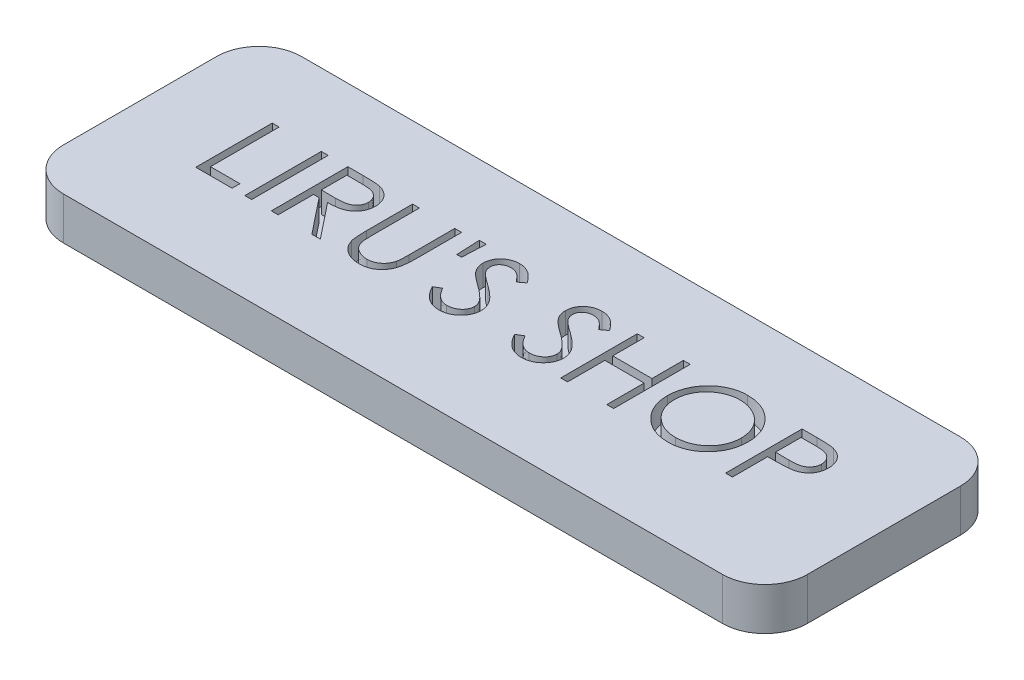
from build123d import *

# Parameters (mm, degrees)
SKETCH1_W           = 175
SKETCH1_H           = 56
BOSS_EXTRUDE1_DEPTH = 10
SKETCH2_W           = 1.615384615
SKETCH2_H           = 18
CUT_EXTRUDE1_DEPTH  = 5
FILLET1_R           = 10


with BuildPart() as part:
    # Sketch1 → Boss-Extrude1 (new body)
    with BuildSketch(Plane(origin=(0, 0, 0), x_dir=(1, 0, 0), z_dir=(0, 1, 0))):
        Rectangle(SKETCH1_W, SKETCH1_H)
    extrude(amount=BOSS_EXTRUDE1_DEPTH)

    # Sketch2 → Cut-Extrude1 (cut)
    with BuildSketch(Plane(origin=(0, 10, 0), x_dir=(1, 0, 0), z_dir=(0, 1, 0))):
        Polygon((-67.384615385, 11), (-65.769230769, 11), (-65.769230769, -5.153846154), (-58.846153846, -5.153846154), (-58.846153846, -7), (-67.384615385, -7), align=None)
        with Locations((-55.038461539, 2)):
            Rectangle(SKETCH2_W, SKETCH2_H)
        with BuildLine():
            Line((-49.615384615, 11), (-46.013221154, 11))
            add(Edge.make_bspline(
                [(-46.013221154, 11), (-45.772838207, 10.999199843), (-45.311276322, 10.997663454), (-44.65004236, 10.989096674), (-44.04921729, 10.964542844), (-43.509115259, 10.943412986), (-43.029746176, 10.904883002), (-42.609640109, 10.868056817), (-42.250731951, 10.819849419), (-42.033467573, 10.775078672), (-41.935096154, 10.754807692)],
                knots=[0, 0, 0, 0, 0.000721163, 0.001384713, 0.001983661, 0.002525115, 0.003006036, 0.003426182, 0.003790275, 0.004091524, 0.004091524, 0.004091524, 0.004091524], degree=3))
            add(Edge.make_bspline(
                [(-41.935096154, 10.754807692), (-41.803404944, 10.722270042), (-41.542831855, 10.657888857), (-41.167660087, 10.52181091), (-40.81015785, 10.364338555), (-40.471810182, 10.179382279), (-40.154311827, 9.965569127), (-39.854389086, 9.726590211), (-39.570680988, 9.463753153), (-39.314661176, 9.170431111), (-39.073260339, 8.86270049), (-38.869661688, 8.529938312), (-38.694154078, 8.181964742), (-38.554419991, 7.815240879), (-38.441904699, 7.433323195), (-38.362569753, 7.03275224), (-38.314992217, 6.61535294), (-38.310148388, 6.330655123), (-38.307692308, 6.186298077)],
                knots=[0, 0, 0, 0, 0.000406701, 0.000804727, 0.001195366, 0.001577816, 0.00195984, 0.002342205, 0.002727415, 0.003118188, 0.003509078, 0.003899318, 0.004286329, 0.00467672, 0.005074941, 0.00547943, 0.005900318, 0.006333251, 0.006333251, 0.006333251, 0.006333251], degree=3))
            add(Edge.make_bspline(
                [(-38.307692308, 6.186298077), (-38.315247155, 5.946460396), (-38.329988619, 5.478474961), (-38.46743201, 4.799304714), (-38.692568397, 4.165759667), (-39.002802454, 3.578637529), (-39.397874044, 3.049382782), (-39.872687255, 2.584517583), (-40.427506971, 2.195512318), (-40.944000596, 1.925755037), (-41.400245052, 1.752991507), (-41.775844946, 1.63143309), (-42.18556083, 1.537514411), (-42.625467123, 1.453376591), (-43.097394494, 1.389853591), (-43.600211839, 1.343328248), (-44.134277762, 1.314250283), (-44.501164404, 1.309919972), (-44.689903846, 1.307692308)],
                knots=[0, 0, 0, 0, 0.000718851, 0.001402665, 0.002068709, 0.00273005, 0.003387023, 0.004042331, 0.00471467, 0.00541297, 0.005783944, 0.00617737, 0.006596291, 0.007043944, 0.007520738, 0.008024128, 0.00855856, 0.00912477, 0.00912477, 0.00912477, 0.00912477], degree=3))
            Line((-44.689903846, 1.307692308), (-38.076923077, -7))
            Line((-38.076923077, -7), (-40.074519231, -7))
            Line((-40.074519231, -7), (-46.6875, 1.307692308))
            Line((-46.6875, 1.307692308), (-48, 1.307692308))
            Line((-48, 1.307692308), (-48, -7))
            Line((-48, -7), (-49.615384615, -7))
            Line((-49.615384615, -7), (-49.615384615, 11))
        make_face()
        with BuildLine():
            Line((-48, 9.153846154), (-48, 3.153846154))
            Line((-48, 3.153846154), (-44.704326923, 3.128605769))
            add(Edge.make_bspline(
                [(-44.704326923, 3.128605769), (-44.550452437, 3.128537695), (-44.252199858, 3.128405748), (-43.820710724, 3.148945168), (-43.41895015, 3.172310805), (-43.048454853, 3.208050296), (-42.709059323, 3.254110094), (-42.400933198, 3.311725441), (-42.123573502, 3.378850335), (-41.800095305, 3.482744411), (-41.438878858, 3.64734679), (-41.046317064, 3.886826498), (-40.712019327, 4.188039111), (-40.429584607, 4.532474027), (-40.202633245, 4.911174736), (-40.042628394, 5.319601777), (-39.941095834, 5.747444281), (-39.929120457, 6.041503122), (-39.923076923, 6.189903846)],
                knots=[0, 0, 0, 0, 0.000461553, 0.00089462, 0.001295656, 0.001668796, 0.002010965, 0.002322838, 0.002608809, 0.002866515, 0.003340999, 0.003796212, 0.004240586, 0.004683802, 0.005128424, 0.005558963, 0.00599544, 0.006440135, 0.006440135, 0.006440135, 0.006440135], degree=3))
            add(Edge.make_bspline(
                [(-39.923076923, 6.189903846), (-39.92925926, 6.334657654), (-39.941510396, 6.621506881), (-40.041532634, 7.041451563), (-40.210678024, 7.437795878), (-40.438620962, 7.808927515), (-40.716330902, 8.145814156), (-41.041965367, 8.434056658), (-41.406620657, 8.671911048), (-41.747443962, 8.823905005), (-42.052077055, 8.917092821), (-42.31657245, 8.982670235), (-42.615431478, 9.035356075), (-42.950105265, 9.07756896), (-43.319165081, 9.11385153), (-43.724477, 9.138289249), (-44.16335187, 9.15276055), (-44.467536088, 9.153475864), (-44.625, 9.153846154)],
                knots=[0, 0, 0, 0, 0.000433908, 0.000859846, 0.001286441, 0.001721799, 0.002162235, 0.002591337, 0.003021392, 0.003463654, 0.003705429, 0.003976533, 0.00428066, 0.004615201, 0.004988342, 0.005392976, 0.005833116, 0.006305486, 0.006305486, 0.006305486, 0.006305486], degree=3))
            Line((-44.625, 9.153846154), (-48, 9.153846154))
        make_face(mode=Mode.SUBTRACT)
        with BuildLine():
            Line((-34.384615385, 11), (-32.769230769, 11))
            Line((-32.769230769, 11), (-32.769230769, 0.215144231))
            add(Edge.make_bspline(
                [(-32.769230769, 0.215144231), (-32.769471167, 0.062500447), (-32.769927363, -0.227167438), (-32.766880148, -0.639461555), (-32.758346254, -1.00600563), (-32.752966005, -1.32821256), (-32.740996861, -1.604603833), (-32.731235477, -1.836676859), (-32.718684042, -2.023332758), (-32.703599438, -2.132263235), (-32.697115385, -2.179086538)],
                knots=[0, 0, 0, 0, 0.000457933, 0.000869006, 0.001236865, 0.00155786, 0.001835715, 0.002066737, 0.002254791, 0.002396567, 0.002396567, 0.002396567, 0.002396567], degree=3))
            add(Edge.make_bspline(
                [(-32.697115385, -2.179086538), (-32.670488454, -2.34801275), (-32.618734924, -2.676346786), (-32.486839267, -3.143875092), (-32.302634976, -3.565236878), (-32.08435647, -3.95358066), (-31.796703041, -4.298097369), (-31.452113431, -4.615471584), (-31.034627764, -4.893040865), (-30.570430363, -5.14684504), (-30.070106285, -5.350836892), (-29.558848343, -5.50508848), (-29.044341593, -5.59909425), (-28.699892745, -5.609979308), (-28.528846154, -5.615384615)],
                knots=[0, 0, 0, 0, 0.000512793, 0.000996692, 0.001452162, 0.001890022, 0.002328164, 0.002792651, 0.003290717, 0.003827989, 0.004377736, 0.004908225, 0.005428119, 0.00594095, 0.00594095, 0.00594095, 0.00594095], degree=3))
            add(Edge.make_bspline(
                [(-28.528846154, -5.615384615), (-28.381998346, -5.609861957), (-28.089150885, -5.598848537), (-27.654032099, -5.530646892), (-27.230260111, -5.407729697), (-26.815742329, -5.249125225), (-26.427194409, -5.039566185), (-26.064399564, -4.797487582), (-25.740585045, -4.513545934), (-25.445086771, -4.199315591), (-25.187764244, -3.844768048), (-24.964712658, -3.457623338), (-24.782007877, -3.032055268), (-24.691784035, -2.732975382), (-24.645432692, -2.579326923)],
                knots=[0, 0, 0, 0, 0.000440627, 0.00087871, 0.001317044, 0.001762324, 0.002207531, 0.002638567, 0.003068002, 0.003496619, 0.003930062, 0.004379092, 0.004834562, 0.005315767, 0.005315767, 0.005315767, 0.005315767], degree=3))
            add(Edge.make_bspline(
                [(-24.645432692, -2.579326923), (-24.630003477, -2.515819969), (-24.595620966, -2.374300883), (-24.563493306, -2.135048532), (-24.530031175, -1.852760374), (-24.506813387, -1.525408194), (-24.484178539, -1.154088906), (-24.470637021, -0.736868154), (-24.464377995, -0.275260927), (-24.462512782, 0.046873048), (-24.461538462, 0.215144231)],
                knots=[0, 0, 0, 0, 0.000195943, 0.00043664, 0.000723338, 0.001048838, 0.001420861, 0.001839379, 0.002300974, 0.002805795, 0.002805795, 0.002805795, 0.002805795], degree=3))
            Line((-24.461538462, 0.215144231), (-24.461538462, 11))
            Line((-24.461538462, 11), (-22.846153846, 11))
            Line((-22.846153846, 11), (-22.846153846, 0.128605769))
            add(Edge.make_bspline(
                [(-22.846153846, 0.128605769), (-22.847460751, -0.067328751), (-22.850011255, -0.44970688), (-22.872128506, -1.010028155), (-22.907393076, -1.541557773), (-22.957217529, -2.044367184), (-23.023236402, -2.516657146), (-23.096651822, -2.962567382), (-23.190146564, -3.378897059), (-23.299346912, -3.76889235), (-23.424182302, -4.140132133), (-23.585879637, -4.492462151), (-23.768062779, -4.836593349), (-23.984138137, -5.167320766), (-24.226939533, -5.486108754), (-24.501833892, -5.791023997), (-24.799729576, -6.086939092), (-25.12557874, -6.366263432), (-25.474010013, -6.622422342), (-25.843986938, -6.847668022), (-26.232667468, -7.038075197), (-26.639041259, -7.194808523), (-27.063281731, -7.312655033), (-27.505399581, -7.40047012), (-27.966401147, -7.45036765), (-28.279933665, -7.45778329), (-28.438701923, -7.461538462)],
                knots=[0, 0, 0, 0, 0.000587785, 0.001147097, 0.001681968, 0.002185706, 0.0026625, 0.003112427, 0.003541074, 0.003941769, 0.004327198, 0.004714546, 0.005103334, 0.00549439, 0.005898252, 0.006304297, 0.006725, 0.007157166, 0.007590609, 0.008021011, 0.008454799, 0.008887386, 0.009325721, 0.009774056, 0.010238347, 0.01071465, 0.01071465, 0.01071465, 0.01071465], degree=3))
            add(Edge.make_bspline(
                [(-28.438701923, -7.461538462), (-28.611857308, -7.457502526), (-28.951587554, -7.449584035), (-29.452183328, -7.404209891), (-29.932084909, -7.318743863), (-30.396360848, -7.209921295), (-30.838690262, -7.059833504), (-31.264999404, -6.884471719), (-31.667986907, -6.669102952), (-32.054190426, -6.429479787), (-32.413289172, -6.159867363), (-32.742932959, -5.866003611), (-33.043666008, -5.552595956), (-33.310419304, -5.216251217), (-33.547612424, -4.859585296), (-33.751939236, -4.481589205), (-33.927378777, -4.082409294), (-34.017926836, -3.804935692), (-34.063701923, -3.664663462)],
                knots=[0, 0, 0, 0, 0.000519544, 0.001019343, 0.001506028, 0.00198091, 0.00244841, 0.002905788, 0.003362242, 0.003817456, 0.004268177, 0.004707459, 0.005141022, 0.005569563, 0.00599359, 0.006424385, 0.006857137, 0.007299576, 0.007299576, 0.007299576, 0.007299576], degree=3))
            add(Edge.make_bspline(
                [(-34.063701923, -3.664663462), (-34.090327308, -3.568838793), (-34.148078361, -3.360992953), (-34.209922749, -3.017005297), (-34.261912311, -2.620928578), (-34.310798039, -2.172735683), (-34.339644109, -1.672079227), (-34.364933794, -1.119176231), (-34.384793547, -0.513358142), (-34.384676432, -0.09136349), (-34.384615385, 0.128605769)],
                knots=[0, 0, 0, 0, 0.000298234, 0.000646877, 0.001047182, 0.001496748, 0.001999, 0.002551259, 0.003157297, 0.003817163, 0.003817163, 0.003817163, 0.003817163], degree=3))
            Line((-34.384615385, 0.128605769), (-34.384615385, 11))
        make_face()
        Polygon((-17.790865385, 5.923076923), (-18.912259615, 5.923076923), (-19.153846154, 11.461538462), (-17.538461538, 11.461538462), align=None)
        with BuildLine():
            Line((-15.230769231, -3.527644231), (-13.709134615, -2.615384615))
            add(Edge.make_bspline(
                [(-13.709134615, -2.615384615), (-13.567612252, -2.852287167), (-13.296460866, -3.306183312), (-12.844139591, -3.919510377), (-12.375456048, -4.440801469), (-11.886939475, -4.867024022), (-11.381571742, -5.202589726), (-10.856053751, -5.440201203), (-10.312156439, -5.588397648), (-9.942005357, -5.606398093), (-9.757211538, -5.615384615)],
                knots=[0, 0, 0, 0, 0.000827491, 0.00158544, 0.002282287, 0.002926439, 0.003525496, 0.004095174, 0.004650532, 0.005204203, 0.005204203, 0.005204203, 0.005204203], degree=3))
            add(Edge.make_bspline(
                [(-9.757211538, -5.615384615), (-9.599393399, -5.610989157), (-9.286518566, -5.60227515), (-8.825912745, -5.518545311), (-8.378577762, -5.389911505), (-7.953733339, -5.205689571), (-7.557241607, -4.98280593), (-7.209550031, -4.713597017), (-6.908970021, -4.412193674), (-6.663094574, -4.075940021), (-6.474454393, -3.714308971), (-6.329466612, -3.343118365), (-6.249006234, -2.956537156), (-6.236885787, -2.696254776), (-6.230769231, -2.564903846)],
                knots=[0, 0, 0, 0, 0.00047303, 0.000937782, 0.001399898, 0.00186673, 0.00232381, 0.002760868, 0.00318157, 0.003596985, 0.004005075, 0.004402201, 0.004789028, 0.005183114, 0.005183114, 0.005183114, 0.005183114], degree=3))
            add(Edge.make_bspline(
                [(-6.230769231, -2.564903846), (-6.2383514, -2.415036619), (-6.253764842, -2.110378446), (-6.384041026, -1.660894517), (-6.588980009, -1.216075585), (-6.778045034, -0.940926219), (-6.876201923, -0.798076923)],
                knots=[0, 0, 0, 0, 0.000448871, 0.00091249, 0.001393248, 0.001912341, 0.001912341, 0.001912341, 0.001912341], degree=3))
            add(Edge.make_bspline(
                [(-6.876201923, -0.798076923), (-6.956793653, -0.694978973), (-7.125985909, -0.478537723), (-7.416853117, -0.156362227), (-7.758164562, 0.175961071), (-8.138239987, 0.531121935), (-8.570924444, 0.892602032), (-9.042665947, 1.27763889), (-9.56550865, 1.671589858), (-9.932191776, 1.935791624), (-10.121394231, 2.072115385)],
                knots=[0, 0, 0, 0, 0.000392499, 0.000824003, 0.001300797, 0.001821328, 0.002384129, 0.002991752, 0.003648011, 0.004347614, 0.004347614, 0.004347614, 0.004347614], degree=3))
            add(Edge.make_bspline(
                [(-10.121394231, 2.072115385), (-10.310774783, 2.207005264), (-10.672855976, 2.464904441), (-11.1792144, 2.847657902), (-11.632014495, 3.197597802), (-12.029243723, 3.518018436), (-12.370727364, 3.80896326), (-12.659156335, 4.067638376), (-12.8871832, 4.301039546), (-13.013983329, 4.452452161), (-13.070913462, 4.520432692)],
                knots=[0, 0, 0, 0, 0.00069749, 0.001333548, 0.001904058, 0.002414259, 0.002864417, 0.00324983, 0.003576226, 0.003842175, 0.003842175, 0.003842175, 0.003842175], degree=3))
            add(Edge.make_bspline(
                [(-13.070913462, 4.520432692), (-13.150486551, 4.626380882), (-13.306977712, 4.834742216), (-13.51354574, 5.160412913), (-13.689118577, 5.493789706), (-13.826753428, 5.835768438), (-13.942653982, 6.181548072), (-14.020609054, 6.535640193), (-14.069421953, 6.896455945), (-14.07442074, 7.139268234), (-14.076923077, 7.260817308)],
                knots=[0, 0, 0, 0, 0.000397388, 0.000781517, 0.001155683, 0.001525973, 0.001886298, 0.002248458, 0.002612069, 0.002976537, 0.002976537, 0.002976537, 0.002976537], degree=3))
            add(Edge.make_bspline(
                [(-14.076923077, 7.260817308), (-14.070210574, 7.451256148), (-14.056929042, 7.828063333), (-13.944606382, 8.378507604), (-13.767317214, 8.90403775), (-13.518943505, 9.399450895), (-13.198762833, 9.851847368), (-12.828240679, 10.266431015), (-12.386924464, 10.614955152), (-11.902710973, 10.91947431), (-11.372706774, 11.157824782), (-10.817324985, 11.337624109), (-10.2356829, 11.439500291), (-9.841723922, 11.454120225), (-9.641826923, 11.461538462)],
                knots=[0, 0, 0, 0, 0.000570851, 0.001129501, 0.00167797, 0.002231076, 0.00278524, 0.003336557, 0.003892933, 0.00446625, 0.005048758, 0.005631477, 0.006213617, 0.006813259, 0.006813259, 0.006813259, 0.006813259], degree=3))
            add(Edge.make_bspline(
                [(-9.641826923, 11.461538462), (-9.429714407, 11.454222482), (-9.007890313, 11.439673333), (-8.387408632, 11.313171744), (-7.790010662, 11.103854003), (-7.3094453, 10.866312334), (-6.933333956, 10.629065053), (-6.646502759, 10.412963099), (-6.355841584, 10.164176826), (-6.059005873, 9.882043561), (-5.761025339, 9.563974555), (-5.457476156, 9.212148155), (-5.147648488, 8.828714439), (-4.948332636, 8.554988435), (-4.846153846, 8.414663462)],
                knots=[0, 0, 0, 0, 0.000635854, 0.00126451, 0.001890555, 0.002530739, 0.002867854, 0.003223384, 0.003607055, 0.004015129, 0.004451308, 0.004913986, 0.005408975, 0.005929656, 0.005929656, 0.005929656, 0.005929656], degree=3))
            Line((-4.846153846, 8.414663462), (-6.306490385, 7.307692308))
            add(Edge.make_bspline(
                [(-6.306490385, 7.307692308), (-6.394669466, 7.421291287), (-6.564481759, 7.640056361), (-6.822290549, 7.946423127), (-7.065283595, 8.226279307), (-7.304685651, 8.469357108), (-7.527852899, 8.68896808), (-7.744454831, 8.876989686), (-7.951374351, 9.035264177), (-8.212204177, 9.204173914), (-8.5398953, 9.371607361), (-8.951244344, 9.513288334), (-9.381116615, 9.598428652), (-9.673897577, 9.609685788), (-9.822115385, 9.615384615)],
                knots=[0, 0, 0, 0, 0.000431368, 0.000830714, 0.001201127, 0.00154282, 0.001853921, 0.002140211, 0.002402715, 0.002634748, 0.003071761, 0.003502797, 0.003936285, 0.004380732, 0.004380732, 0.004380732, 0.004380732], degree=3))
            add(Edge.make_bspline(
                [(-9.822115385, 9.615384615), (-10.008063214, 9.609153016), (-10.366646087, 9.597135963), (-10.875738729, 9.465890324), (-11.333936058, 9.259240757), (-11.727634964, 8.969620869), (-12.055425132, 8.626484335), (-12.29253892, 8.231621652), (-12.435254052, 7.795597867), (-12.452669204, 7.491440778), (-12.461538462, 7.336538462)],
                knots=[0, 0, 0, 0, 0.000556703, 0.00107355, 0.001565641, 0.002056079, 0.002530563, 0.002980129, 0.003427128, 0.003891041, 0.003891041, 0.003891041, 0.003891041], degree=3))
            add(Edge.make_bspline(
                [(-12.461538462, 7.336538462), (-12.459516667, 7.240102286), (-12.455469773, 7.047072243), (-12.399027956, 6.761893502), (-12.326517122, 6.477435185), (-12.211612159, 6.194976187), (-12.052979168, 5.909576627), (-11.844666835, 5.616321976), (-11.582312659, 5.312627475), (-11.381345167, 5.115103838), (-11.275240385, 5.010817308)],
                knots=[0, 0, 0, 0, 0.000288822, 0.000578116, 0.000869381, 0.001168682, 0.001489838, 0.001846973, 0.002245896, 0.002692094, 0.002692094, 0.002692094, 0.002692094], degree=3))
            add(Edge.make_bspline(
                [(-11.275240385, 5.010817308), (-11.235839041, 4.975655461), (-11.142230467, 4.892118961), (-10.971097135, 4.75535866), (-10.745105601, 4.586658688), (-10.470157138, 4.377923918), (-10.141182134, 4.135790684), (-9.758144417, 3.863354965), (-9.325313677, 3.551772604), (-9.018172395, 3.333933824), (-8.855769231, 3.21875)],
                knots=[0, 0, 0, 0, 0.000158408, 0.000376341, 0.000656873, 0.00100447, 0.001411938, 0.001882239, 0.002414575, 0.003011883, 0.003011883, 0.003011883, 0.003011883], degree=3))
            add(Edge.make_bspline(
                [(-8.855769231, 3.21875), (-8.660413105, 3.076594437), (-8.282133044, 2.80132989), (-7.743894061, 2.387763536), (-7.255868763, 1.983289298), (-6.816343716, 1.590490175), (-6.420976758, 1.212345697), (-6.074154195, 0.844306484), (-5.772342124, 0.489009253), (-5.447420429, 0.03349315), (-5.115408786, -0.525952427), (-4.830281034, -1.211383368), (-4.650495247, -1.89947873), (-4.626984596, -2.361959604), (-4.615384615, -2.590144231)],
                knots=[0, 0, 0, 0, 0.000724795, 0.001403466, 0.002035957, 0.002625862, 0.003171585, 0.00367665, 0.004142479, 0.004568769, 0.005354164, 0.006088078, 0.006790324, 0.007474252, 0.007474252, 0.007474252, 0.007474252], degree=3))
            add(Edge.make_bspline(
                [(-4.615384615, -2.590144231), (-4.618764183, -2.75151868), (-4.625457689, -3.071133795), (-4.702399531, -3.540445619), (-4.815129238, -3.99626152), (-4.985035012, -4.432947242), (-5.192411255, -4.858491735), (-5.455551958, -5.261732366), (-5.760562908, -5.651593844), (-6.110450842, -6.017680371), (-6.493315483, -6.353746522), (-6.897974484, -6.652695981), (-7.325090173, -6.901961644), (-7.772345516, -7.105365975), (-8.239843248, -7.264452637), (-8.727426136, -7.379718821), (-9.235897908, -7.450462477), (-9.581500385, -7.45780525), (-9.757211538, -7.461538462)],
                knots=[0, 0, 0, 0, 0.000483657, 0.000957922, 0.001423178, 0.001889941, 0.002360808, 0.002840903, 0.003331407, 0.003844048, 0.004357602, 0.004858116, 0.005350999, 0.005838312, 0.006329769, 0.006830036, 0.007339472, 0.007866358, 0.007866358, 0.007866358, 0.007866358], degree=3))
            add(Edge.make_bspline(
                [(-9.757211538, -7.461538462), (-9.893164731, -7.458909528), (-10.163358926, -7.453684768), (-10.563007689, -7.407495326), (-10.95458272, -7.342144508), (-11.333170456, -7.238392148), (-11.703648573, -7.112510552), (-12.064405779, -6.957513413), (-12.415616913, -6.771767805), (-12.759250196, -6.559393393), (-13.094431666, -6.312239278), (-13.418017501, -6.024375582), (-13.74062474, -5.703741556), (-14.05273135, -5.341630088), (-14.360650378, -4.943891376), (-14.65831077, -4.506804147), (-14.951873889, -4.032749185), (-15.136067724, -3.699157315), (-15.230769231, -3.527644231)],
                knots=[0, 0, 0, 0, 0.000407707, 0.00081028, 0.001205683, 0.001597519, 0.001986358, 0.002378857, 0.002774014, 0.003177248, 0.003589758, 0.004021563, 0.004475403, 0.004953341, 0.005454594, 0.005983673, 0.006539031, 0.007126717, 0.007126717, 0.007126717, 0.007126717], degree=3))
        make_face()
        with BuildLine():
            Line((4.153846154, -3.527644231), (5.675480769, -2.615384615))
            add(Edge.make_bspline(
                [(5.675480769, -2.615384615), (5.817003132, -2.852287167), (6.088154518, -3.306183312), (6.540475794, -3.919510377), (7.009159337, -4.440801469), (7.49767591, -4.867024022), (8.003043643, -5.202589726), (8.528561633, -5.440201203), (9.072458946, -5.588397648), (9.442610028, -5.606398093), (9.627403846, -5.615384615)],
                knots=[0, 0, 0, 0, 0.000827491, 0.00158544, 0.002282287, 0.002926439, 0.003525496, 0.004095174, 0.004650532, 0.005204203, 0.005204203, 0.005204203, 0.005204203], degree=3))
            add(Edge.make_bspline(
                [(9.627403846, -5.615384615), (9.785221986, -5.610989157), (10.098096819, -5.60227515), (10.55870264, -5.518545311), (11.006037623, -5.389911505), (11.430882045, -5.205689571), (11.827373777, -4.98280593), (12.175065353, -4.713597017), (12.475645364, -4.412193674), (12.72152081, -4.075940021), (12.910160992, -3.714308971), (13.055148772, -3.343118365), (13.135609151, -2.956537156), (13.147729597, -2.696254776), (13.153846154, -2.564903846)],
                knots=[0, 0, 0, 0, 0.00047303, 0.000937782, 0.001399898, 0.00186673, 0.00232381, 0.002760868, 0.00318157, 0.003596985, 0.004005075, 0.004402201, 0.004789028, 0.005183114, 0.005183114, 0.005183114, 0.005183114], degree=3))
            add(Edge.make_bspline(
                [(13.153846154, -2.564903846), (13.146263985, -2.415036619), (13.130850542, -2.110378446), (13.000574359, -1.660894517), (12.795635375, -1.216075585), (12.606570351, -0.940926219), (12.508413462, -0.798076923)],
                knots=[0, 0, 0, 0, 0.000448871, 0.00091249, 0.001393248, 0.001912341, 0.001912341, 0.001912341, 0.001912341], degree=3))
            add(Edge.make_bspline(
                [(12.508413462, -0.798076923), (12.427821731, -0.694978973), (12.258629475, -0.478537723), (11.967762267, -0.156362227), (11.626450822, 0.175961071), (11.246375397, 0.531121935), (10.81369094, 0.892602032), (10.341949438, 1.27763889), (9.819106734, 1.671589858), (9.452423609, 1.935791624), (9.263221154, 2.072115385)],
                knots=[0, 0, 0, 0, 0.000392499, 0.000824003, 0.001300797, 0.001821328, 0.002384129, 0.002991752, 0.003648011, 0.004347614, 0.004347614, 0.004347614, 0.004347614], degree=3))
            add(Edge.make_bspline(
                [(9.263221154, 2.072115385), (9.073840602, 2.207005264), (8.711759408, 2.464904441), (8.205400985, 2.847657902), (7.752600889, 3.197597802), (7.355371661, 3.518018436), (7.01388802, 3.80896326), (6.72545905, 4.067638376), (6.497432185, 4.301039546), (6.370632055, 4.452452161), (6.313701923, 4.520432692)],
                knots=[0, 0, 0, 0, 0.00069749, 0.001333548, 0.001904058, 0.002414259, 0.002864417, 0.00324983, 0.003576226, 0.003842175, 0.003842175, 0.003842175, 0.003842175], degree=3))
            add(Edge.make_bspline(
                [(6.313701923, 4.520432692), (6.234128833, 4.626380882), (6.077637673, 4.834742216), (5.871069645, 5.160412913), (5.695496808, 5.493789706), (5.557861957, 5.835768438), (5.441961403, 6.181548072), (5.36400633, 6.535640193), (5.315193432, 6.896455945), (5.310194644, 7.139268234), (5.307692308, 7.260817308)],
                knots=[0, 0, 0, 0, 0.000397388, 0.000781517, 0.001155683, 0.001525973, 0.001886298, 0.002248458, 0.002612069, 0.002976537, 0.002976537, 0.002976537, 0.002976537], degree=3))
            add(Edge.make_bspline(
                [(5.307692308, 7.260817308), (5.314404811, 7.451256148), (5.327686343, 7.828063333), (5.440009003, 8.378507604), (5.61729817, 8.90403775), (5.865671879, 9.399450895), (6.185852552, 9.851847368), (6.556374705, 10.266431015), (6.99769092, 10.614955152), (7.481904411, 10.91947431), (8.011908611, 11.157824782), (8.5672904, 11.337624109), (9.148932484, 11.439500291), (9.542891462, 11.454120225), (9.742788462, 11.461538462)],
                knots=[0, 0, 0, 0, 0.000570851, 0.001129501, 0.00167797, 0.002231076, 0.00278524, 0.003336557, 0.003892933, 0.00446625, 0.005048758, 0.005631477, 0.006213617, 0.006813259, 0.006813259, 0.006813259, 0.006813259], degree=3))
            add(Edge.make_bspline(
                [(9.742788462, 11.461538462), (9.954900977, 11.454222482), (10.376725072, 11.439673333), (10.997206752, 11.313171744), (11.594604722, 11.103854003), (12.075170084, 10.866312334), (12.451281429, 10.629065053), (12.738112625, 10.412963099), (13.028773801, 10.164176826), (13.325609511, 9.882043561), (13.623590046, 9.563974555), (13.927139229, 9.212148155), (14.236966897, 8.828714439), (14.436282749, 8.554988435), (14.538461538, 8.414663462)],
                knots=[0, 0, 0, 0, 0.000635854, 0.00126451, 0.001890555, 0.002530739, 0.002867854, 0.003223384, 0.003607055, 0.004015129, 0.004451308, 0.004913986, 0.005408975, 0.005929656, 0.005929656, 0.005929656, 0.005929656], degree=3))
            Line((14.538461538, 8.414663462), (13.078125, 7.307692308))
            add(Edge.make_bspline(
                [(13.078125, 7.307692308), (12.989945919, 7.421291287), (12.820133625, 7.640056361), (12.562324836, 7.946423127), (12.319331789, 8.226279307), (12.079929733, 8.469357108), (11.856762486, 8.68896808), (11.640160554, 8.876989686), (11.433241033, 9.035264177), (11.172411207, 9.204173914), (10.844720084, 9.371607361), (10.433371041, 9.513288334), (10.003498769, 9.598428652), (9.710717807, 9.609685788), (9.5625, 9.615384615)],
                knots=[0, 0, 0, 0, 0.000431368, 0.000830714, 0.001201127, 0.00154282, 0.001853921, 0.002140211, 0.002402715, 0.002634748, 0.003071761, 0.003502797, 0.003936285, 0.004380732, 0.004380732, 0.004380732, 0.004380732], degree=3))
            add(Edge.make_bspline(
                [(9.5625, 9.615384615), (9.37655217, 9.609153016), (9.017969298, 9.597135963), (8.508876655, 9.465890324), (8.050679326, 9.259240757), (7.65698042, 8.969620869), (7.329190253, 8.626484335), (7.092076465, 8.231621652), (6.949361333, 7.795597867), (6.93194618, 7.491440778), (6.923076923, 7.336538462)],
                knots=[0, 0, 0, 0, 0.000556703, 0.00107355, 0.001565641, 0.002056079, 0.002530563, 0.002980129, 0.003427128, 0.003891041, 0.003891041, 0.003891041, 0.003891041], degree=3))
            add(Edge.make_bspline(
                [(6.923076923, 7.336538462), (6.925098717, 7.240102286), (6.929145611, 7.047072243), (6.985587428, 6.761893502), (7.058098263, 6.477435185), (7.173003226, 6.194976187), (7.331636216, 5.909576627), (7.539948549, 5.616321976), (7.802302726, 5.312627475), (8.003270218, 5.115103838), (8.109375, 5.010817308)],
                knots=[0, 0, 0, 0, 0.000288822, 0.000578116, 0.000869381, 0.001168682, 0.001489838, 0.001846973, 0.002245896, 0.002692094, 0.002692094, 0.002692094, 0.002692094], degree=3))
            add(Edge.make_bspline(
                [(8.109375, 5.010817308), (8.148776344, 4.975655461), (8.242384918, 4.892118961), (8.41351825, 4.75535866), (8.639509784, 4.586658688), (8.914458247, 4.377923918), (9.24343325, 4.135790684), (9.626470967, 3.863354965), (10.059301708, 3.551772604), (10.36644299, 3.333933824), (10.528846154, 3.21875)],
                knots=[0, 0, 0, 0, 0.000158408, 0.000376341, 0.000656873, 0.00100447, 0.001411938, 0.001882239, 0.002414575, 0.003011883, 0.003011883, 0.003011883, 0.003011883], degree=3))
            add(Edge.make_bspline(
                [(10.528846154, 3.21875), (10.724202279, 3.076594437), (11.102482341, 2.80132989), (11.640721323, 2.387763536), (12.128746622, 1.983289298), (12.568271669, 1.590490175), (12.963638627, 1.212345697), (13.31046119, 0.844306484), (13.61227326, 0.489009253), (13.937194955, 0.03349315), (14.269206599, -0.525952427), (14.554334351, -1.211383368), (14.734120138, -1.89947873), (14.757630789, -2.361959604), (14.769230769, -2.590144231)],
                knots=[0, 0, 0, 0, 0.000724795, 0.001403466, 0.002035957, 0.002625862, 0.003171585, 0.00367665, 0.004142479, 0.004568769, 0.005354164, 0.006088078, 0.006790324, 0.007474252, 0.007474252, 0.007474252, 0.007474252], degree=3))
            add(Edge.make_bspline(
                [(14.769230769, -2.590144231), (14.765851202, -2.75151868), (14.759157696, -3.071133795), (14.682215853, -3.540445619), (14.569486147, -3.99626152), (14.399580372, -4.432947242), (14.19220413, -4.858491735), (13.929063426, -5.261732366), (13.624052476, -5.651593844), (13.274164543, -6.017680371), (12.891299902, -6.353746522), (12.486640901, -6.652695981), (12.059525212, -6.901961644), (11.612269869, -7.105365975), (11.144772137, -7.264452637), (10.657189249, -7.379718821), (10.148717477, -7.450462477), (9.803115, -7.45780525), (9.627403846, -7.461538462)],
                knots=[0, 0, 0, 0, 0.000483657, 0.000957922, 0.001423178, 0.001889941, 0.002360808, 0.002840903, 0.003331407, 0.003844048, 0.004357602, 0.004858116, 0.005350999, 0.005838312, 0.006329769, 0.006830036, 0.007339472, 0.007866358, 0.007866358, 0.007866358, 0.007866358], degree=3))
            add(Edge.make_bspline(
                [(9.627403846, -7.461538462), (9.491450654, -7.458909528), (9.221256459, -7.453684768), (8.821607695, -7.407495326), (8.430032665, -7.342144508), (8.051444929, -7.238392148), (7.680966812, -7.112510552), (7.320209606, -6.957513413), (6.968998472, -6.771767805), (6.625365188, -6.559393393), (6.290183719, -6.312239278), (5.966597884, -6.024375582), (5.643990644, -5.703741556), (5.331884034, -5.341630088), (5.023965007, -4.943891376), (4.726304615, -4.506804147), (4.432741495, -4.032749185), (4.248547661, -3.699157315), (4.153846154, -3.527644231)],
                knots=[0, 0, 0, 0, 0.000407707, 0.00081028, 0.001205683, 0.001597519, 0.001986358, 0.002378857, 0.002774014, 0.003177248, 0.003589758, 0.004021563, 0.004475403, 0.004953341, 0.005454594, 0.005983673, 0.006539031, 0.007126717, 0.007126717, 0.007126717, 0.007126717], degree=3))
        make_face()
        Polygon((18.461538462, 11), (20.076923077, 11), (20.076923077, 3.615384615), (29.307692308, 3.615384615), (29.307692308, 11), (30.923076923, 11), (30.923076923, -7), (29.307692308, -7), (29.307692308, 1.769230769), (20.076923077, 1.769230769), (20.076923077, -7), (18.461538462, -7), align=None)
        with BuildLine():
            add(Edge.make_bspline(
                [(43.961538462, 11.461538462), (44.294837292, 11.453096568), (44.949463693, 11.436515992), (45.911563167, 11.309594888), (46.830052229, 11.090018596), (47.712412943, 10.797580401), (48.548091108, 10.407472133), (49.343376841, 9.935948513), (50.096377906, 9.378069582), (50.796945011, 8.738147844), (51.438037898, 8.041890081), (52.002856742, 7.298860829), (52.47621711, 6.513552703), (52.864944015, 5.688325574), (53.169908294, 4.825045739), (53.38034909, 3.919110868), (53.514773862, 2.976390747), (53.530489289, 2.333395443), (53.538461538, 2.007211538)],
                knots=[0, 0, 0, 0, 0.000999735, 0.001963562, 0.002904633, 0.003829378, 0.004747327, 0.005665638, 0.006598829, 0.007553507, 0.008507954, 0.009434643, 0.010348619, 0.011253502, 0.012166958, 0.013089654, 0.01403967, 0.015017791, 0.015017791, 0.015017791, 0.015017791], degree=3))
            add(Edge.make_bspline(
                [(53.538461538, 2.007211538), (53.530490457, 1.683430386), (53.514778532, 1.045220224), (53.380196247, 0.108482511), (53.169128247, -0.791983928), (52.867776021, -1.654675857), (52.480902132, -2.480503328), (52.004389823, -3.267293376), (51.443092168, -4.015303939), (50.804314077, -4.716340503), (50.107965861, -5.359184638), (49.361067346, -5.919338856), (48.580415986, -6.40134864), (47.755966059, -6.785950392), (46.898651584, -7.09334884), (46.000799636, -7.302933794), (45.066617358, -7.438124302), (44.429566482, -7.453648099), (44.105769231, -7.461538462)],
                knots=[0, 0, 0, 0, 0.000970917, 0.001913789, 0.002832977, 0.003741839, 0.004649984, 0.00556396, 0.006496412, 0.00745109, 0.008405536, 0.009335105, 0.01024787, 0.011152753, 0.012059409, 0.01297509, 0.013914391, 0.014885307, 0.014885307, 0.014885307, 0.014885307], degree=3))
            add(Edge.make_bspline(
                [(44.105769231, -7.461538462), (43.779587019, -7.453570186), (43.136595051, -7.437862595), (42.192690298, -7.30321537), (41.286119044, -7.092660093), (40.419473809, -6.791754421), (39.592271314, -6.402865806), (38.802893746, -5.928671857), (38.05450956, -5.366006559), (37.353323435, -4.727435604), (36.71175613, -4.032267622), (36.152422198, -3.287405739), (35.678121615, -2.507463391), (35.290538762, -1.690276124), (34.983692972, -0.839794418), (34.774353907, 0.049654894), (34.638911868, 0.973000924), (34.623304086, 1.601678687), (34.615384615, 1.920673077)],
                knots=[0, 0, 0, 0, 0.000978121, 0.001928137, 0.002854342, 0.003766609, 0.004674755, 0.005591819, 0.006524271, 0.007478949, 0.008433396, 0.009357915, 0.010268806, 0.011167171, 0.012067032, 0.0129757, 0.013904289, 0.014860797, 0.014860797, 0.014860797, 0.014860797], degree=3))
            add(Edge.make_bspline(
                [(34.615384615, 1.920673077), (34.618134169, 2.134783947), (34.623598591, 2.560304582), (34.689384438, 3.192189954), (34.784844615, 3.813913337), (34.921654451, 4.423706784), (35.100583024, 5.020077562), (35.311707737, 5.607138628), (35.569569798, 6.178940636), (35.861070274, 6.738192365), (36.186416715, 7.27617588), (36.545777712, 7.784699451), (36.926531036, 8.268030292), (37.343942775, 8.713643454), (37.784255921, 9.134502258), (38.254613295, 9.524139089), (38.752144837, 9.886067408), (39.278991362, 10.212229162), (39.822171061, 10.507218997), (40.382108775, 10.760359945), (40.951199714, 10.977625404), (41.532109332, 11.153721077), (42.123295017, 11.292742976), (42.726047052, 11.387409367), (43.339885245, 11.453363002), (43.753429171, 11.458801583), (43.961538462, 11.461538462)],
                knots=[0, 0, 0, 0, 0.00064208, 0.00127606, 0.001903847, 0.002528437, 0.003149069, 0.003770738, 0.004398618, 0.005029226, 0.00566184, 0.006283059, 0.006896305, 0.007506106, 0.008113119, 0.008722526, 0.009337032, 0.009957361, 0.010580105, 0.011190067, 0.011799474, 0.012406294, 0.013009795, 0.013619777, 0.014235815, 0.014859874, 0.014859874, 0.014859874, 0.014859874], degree=3))
        make_face()
        with BuildLine():
            add(Edge.make_bspline(
                [(44.040865385, 9.615384615), (43.870047269, 9.613302323), (43.530044071, 9.609157644), (43.024580742, 9.554562535), (42.525765082, 9.476751678), (42.033494077, 9.365761), (41.549827446, 9.214540157), (41.070256834, 9.0405012), (40.599155414, 8.82850702), (40.138078431, 8.588990255), (39.691086616, 8.323881519), (39.269307008, 8.03088386), (38.871647697, 7.716868438), (38.499082325, 7.381102418), (38.152704868, 7.021875894), (37.825697832, 6.644634794), (37.531168555, 6.238596497), (37.261242732, 5.814771548), (37.019693839, 5.373711987), (36.804900586, 4.920061267), (36.629199969, 4.450118878), (36.485907748, 3.96898321), (36.367108721, 3.477416275), (36.29184854, 2.971689052), (36.236653548, 2.454342762), (36.232745772, 2.104721798), (36.230769231, 1.927884615)],
                knots=[0, 0, 0, 0, 0.000512222, 0.001019548, 0.001523427, 0.00202639, 0.002531674, 0.003042753, 0.00355604, 0.004080181, 0.004600862, 0.005113972, 0.005619667, 0.006120051, 0.006617295, 0.007115948, 0.007616462, 0.008120612, 0.008622488, 0.009124157, 0.009625099, 0.010125886, 0.010629663, 0.011140665, 0.011658755, 0.012189, 0.012189, 0.012189, 0.012189], degree=3))
            add(Edge.make_bspline(
                [(36.230769231, 1.927884615), (36.237325664, 1.667850337), (36.250224196, 1.156282467), (36.363148842, 0.406617727), (36.537090425, -0.313836317), (36.793499738, -1.001137565), (37.114160042, -1.661193876), (37.510298335, -2.288149843), (37.979630775, -2.882174912), (38.512757483, -3.439122009), (39.095559974, -3.94747186), (39.714414014, -4.393683675), (40.362689709, -4.771222103), (41.042077609, -5.078791047), (41.748950667, -5.322509698), (42.487863786, -5.489542658), (43.253894721, -5.599473572), (43.776052377, -5.610030602), (44.040865385, -5.615384615)],
                knots=[0, 0, 0, 0, 0.00077968, 0.001533873, 0.002269352, 0.002999465, 0.003729978, 0.004467267, 0.00521963, 0.005997482, 0.006776971, 0.007536497, 0.008282961, 0.009023628, 0.00977051, 0.010521844, 0.011293386, 0.012087318, 0.012087318, 0.012087318, 0.012087318], degree=3))
            add(Edge.make_bspline(
                [(44.040865385, -5.615384615), (44.218857107, -5.612939164), (44.571868151, -5.608089101), (45.096930838, -5.559238762), (45.612534212, -5.480903434), (46.11795508, -5.368117205), (46.612619825, -5.226960144), (47.098593098, -5.059263257), (47.570698591, -4.850045638), (48.034892042, -4.618884744), (48.479215571, -4.355363934), (48.903375451, -4.072310593), (49.296680491, -3.758757686), (49.668967144, -3.427980365), (50.016766687, -3.073309147), (50.337727177, -2.695205149), (50.630767857, -2.291281769), (50.900591182, -1.868099682), (51.141293677, -1.42583324), (51.351014757, -0.970537753), (51.528937639, -0.503334334), (51.672569949, -0.023549109), (51.785123752, 0.467906685), (51.862677626, 0.971691087), (51.916926739, 1.486796277), (51.921015708, 1.83519325), (51.923076923, 2.010817308)],
                knots=[0, 0, 0, 0, 0.000533849, 0.001058782, 0.001580474, 0.002097509, 0.002611125, 0.003123157, 0.00363829, 0.004159146, 0.004677989, 0.005187028, 0.005687659, 0.006185634, 0.006680295, 0.007176609, 0.007672085, 0.008176235, 0.008681274, 0.009181425, 0.009678995, 0.010179781, 0.010682744, 0.011190185, 0.011708275, 0.012234915, 0.012234915, 0.012234915, 0.012234915], degree=3))
            add(Edge.make_bspline(
                [(51.923076923, 2.010817308), (51.921014056, 2.185239901), (51.91692198, 2.531239245), (51.862703539, 3.042752025), (51.785041817, 3.542911398), (51.673119319, 4.029753814), (51.528861385, 4.503403371), (51.350983686, 4.963415216), (51.141230717, 5.411503077), (50.900502706, 5.846559461), (50.629907043, 6.264029543), (50.334222363, 6.663127664), (50.00834343, 7.036358905), (49.661581016, 7.392937332), (49.285273606, 7.725257907), (48.881125808, 8.03343087), (48.454044036, 8.324893424), (48.001846825, 8.587824885), (47.535163635, 8.830640938), (47.056291851, 9.038674669), (46.570656481, 9.215445569), (46.079492475, 9.366218532), (45.578665729, 9.476316973), (45.071560324, 9.554632658), (44.558877851, 9.609138642), (44.21408415, 9.613296017), (44.040865385, 9.615384615)],
                knots=[0, 0, 0, 0, 0.000523035, 0.001037537, 0.001541417, 0.002040865, 0.00253475, 0.003025585, 0.003519193, 0.004017912, 0.004515991, 0.005010705, 0.005506626, 0.006001287, 0.006501957, 0.007011124, 0.007525171, 0.008052057, 0.0085794, 0.009102585, 0.009617049, 0.010129233, 0.010642748, 0.011153751, 0.011668252, 0.012187684, 0.012187684, 0.012187684, 0.012187684], degree=3))
        make_face(mode=Mode.SUBTRACT)
        with BuildLine():
            Line((57.230769231, 11), (60.760817308, 11))
            add(Edge.make_bspline(
                [(60.760817308, 11), (61.003616254, 10.999733105), (61.468829817, 10.999221722), (62.135935817, 10.983717315), (62.741814437, 10.963008613), (63.285159253, 10.934301734), (63.767642044, 10.900376413), (64.187079584, 10.852794496), (64.546768731, 10.803112976), (64.762287614, 10.752602885), (64.860576923, 10.729567308)],
                knots=[0, 0, 0, 0, 0.000728374, 0.001395598, 0.002001753, 0.002546988, 0.003027909, 0.00345238, 0.003813425, 0.004116138, 0.004116138, 0.004116138, 0.004116138], degree=3))
            add(Edge.make_bspline(
                [(64.860576923, 10.729567308), (64.985000811, 10.695511566), (65.230916694, 10.628202563), (65.585264916, 10.493389128), (65.922398978, 10.333537992), (66.243475564, 10.15135773), (66.544549134, 9.939031972), (66.830111631, 9.705167652), (67.097642958, 9.444365299), (67.345638688, 9.159550066), (67.573389075, 8.855503272), (67.769484586, 8.52768609), (67.933681754, 8.181616529), (68.074510007, 7.817535306), (68.175867773, 7.432385071), (68.252223257, 7.028841979), (68.300687628, 6.606949286), (68.305329374, 6.318641396), (68.307692308, 6.171875)],
                knots=[0, 0, 0, 0, 0.000386827, 0.000764539, 0.001135513, 0.001505381, 0.001870491, 0.002239373, 0.002611659, 0.00298987, 0.003371366, 0.003749818, 0.004133659, 0.004519392, 0.004919128, 0.005326468, 0.00575094, 0.00619108, 0.00619108, 0.00619108, 0.00619108], degree=3))
            add(Edge.make_bspline(
                [(68.307692308, 6.171875), (68.305524981, 6.023875005), (68.301284459, 5.734303019), (68.250389277, 5.310671537), (68.181834006, 4.905834102), (68.076420594, 4.520688357), (67.938357132, 4.157521537), (67.776398003, 3.810783772), (67.581054133, 3.486374031), (67.356595008, 3.18311457), (67.106901094, 2.900720735), (66.833028841, 2.641238935), (66.536083908, 2.406188051), (66.217010004, 2.195041141), (65.872696495, 2.012694561), (65.50836542, 1.849371278), (65.120850021, 1.712205824), (64.852688521, 1.640051222), (64.716346154, 1.603365385)],
                knots=[0, 0, 0, 0, 0.000443744, 0.000868215, 0.00127845, 0.001674707, 0.002063813, 0.002442848, 0.002821299, 0.003197752, 0.003573255, 0.003950743, 0.004328041, 0.00470807, 0.005096858, 0.005495552, 0.005904978, 0.006328452, 0.006328452, 0.006328452, 0.006328452], degree=3))
            add(Edge.make_bspline(
                [(64.716346154, 1.603365385), (64.603577008, 1.579384339), (64.356436867, 1.526828483), (63.949417153, 1.46815642), (63.475526597, 1.41807733), (62.935412014, 1.380528623), (62.329558217, 1.348383871), (61.657637465, 1.322833674), (60.918330783, 1.308794425), (60.402650099, 1.308070348), (60.133413462, 1.307692308)],
                knots=[0, 0, 0, 0, 0.000345797, 0.000757834, 0.001232879, 0.001775197, 0.002381835, 0.003052983, 0.003792306, 0.004600007, 0.004600007, 0.004600007, 0.004600007], degree=3))
            Line((60.133413462, 1.307692308), (58.846153846, 1.307692308))
            Line((58.846153846, 1.307692308), (58.846153846, -7))
            Line((58.846153846, -7), (57.230769231, -7))
            Line((57.230769231, -7), (57.230769231, 11))
        make_face()
        with BuildLine():
            Line((58.846153846, 9.153846154), (58.846153846, 3.153846154))
            Line((58.846153846, 3.153846154), (61.997596154, 3.114182692))
            add(Edge.make_bspline(
                [(61.997596154, 3.114182692), (62.151470058, 3.114103165), (62.448520458, 3.11394964), (62.877621034, 3.134445075), (63.27572594, 3.158104957), (63.641612328, 3.192746849), (63.975445134, 3.241713316), (64.277780997, 3.291145111), (64.546275595, 3.362658405), (64.860500061, 3.458948475), (65.210642991, 3.623173355), (65.591561812, 3.861544218), (65.91438197, 4.16538786), (66.19373321, 4.507016707), (66.415420583, 4.887069373), (66.577708543, 5.293709619), (66.673063067, 5.722767131), (66.685849206, 6.016363273), (66.692307692, 6.164663462)],
                knots=[0, 0, 0, 0, 0.000461553, 0.000891018, 0.001288455, 0.001658006, 0.001993033, 0.002300708, 0.00257619, 0.002825927, 0.003285786, 0.003731868, 0.004168226, 0.004609163, 0.005051954, 0.005482492, 0.005918179, 0.006362874, 0.006362874, 0.006362874, 0.006362874], degree=3))
            add(Edge.make_bspline(
                [(66.692307692, 6.164663462), (66.685814082, 6.309375816), (66.672905588, 6.597046068), (66.576961149, 7.018651122), (66.415736106, 7.421006173), (66.192245048, 7.796296326), (65.921004951, 8.13669589), (65.605751187, 8.4323954), (65.247225843, 8.670107014), (64.913720655, 8.82353532), (64.617485984, 8.917213879), (64.360178761, 8.982758773), (64.069655293, 9.035090462), (63.745820998, 9.077465048), (63.391185852, 9.113739992), (63.00270309, 9.138353589), (62.581844353, 9.152761078), (62.289675703, 9.153475705), (62.138221154, 9.153846154)],
                knots=[0, 0, 0, 0, 0.000433908, 0.000862555, 0.001289743, 0.001729425, 0.002168101, 0.002591621, 0.003020647, 0.003453054, 0.003687955, 0.003952064, 0.004249097, 0.004572915, 0.004931702, 0.005318344, 0.005740466, 0.006194807, 0.006194807, 0.006194807, 0.006194807], degree=3))
            Line((62.138221154, 9.153846154), (58.846153846, 9.153846154))
        make_face(mode=Mode.SUBTRACT)
    extrude(amount=-CUT_EXTRUDE1_DEPTH, mode=Mode.SUBTRACT)

    # Fillet1
    fillet1_edges = [part.edges().sort_by_distance(p)[0] for p in [
        (87.5, 5, 28),
        (-87.5, 5, 28),
        (-87.5, 5, -28),
        (87.5, 5, -28),
    ]]
    fillet(fillet1_edges, radius=FILLET1_R)


solid = part.part
